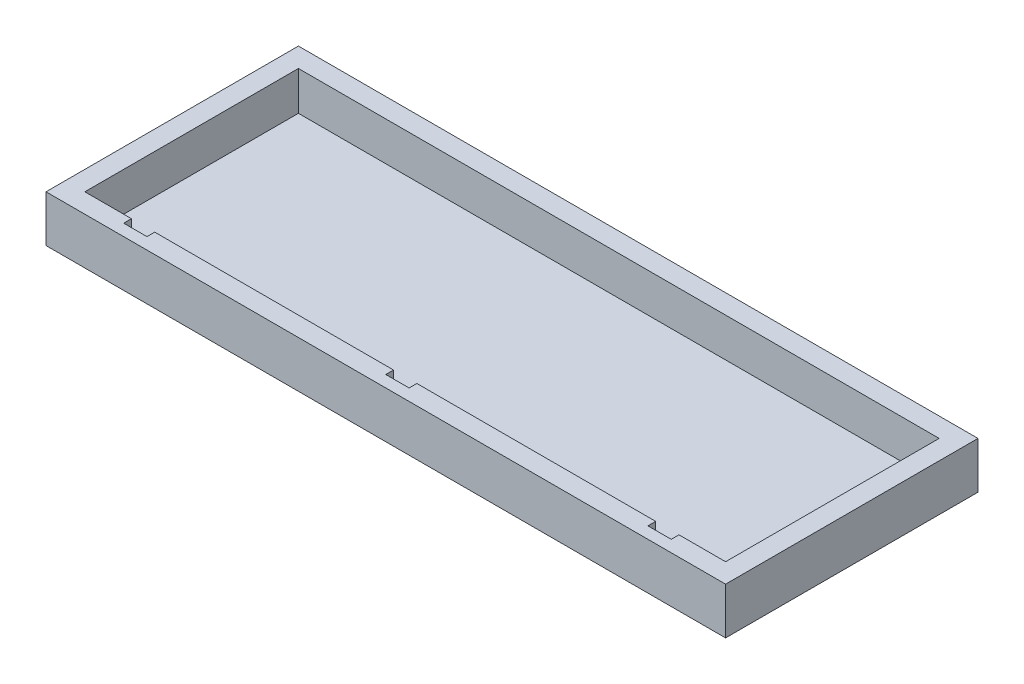
from build123d import *

# Parameters (mm, degrees)
SKETCH1_W           = 175
SKETCH1_H           = 65
BOSS_EXTRUDE1_DEPTH = 12
SKETCH2_W           = 165
SKETCH2_H           = 55
CUT_EXTRUDE1_DEPTH  = 10
SKETCH5_W           = 6
SKETCH5_H           = 10
CUT_EXTRUDE2_DEPTH  = 2
SKETCH6_W           = 6
SKETCH6_H           = 10
CUT_EXTRUDE3_DEPTH  = 2
SKETCH7_W           = 6
SKETCH7_H           = 10
CUT_EXTRUDE4_DEPTH  = 2


with BuildPart() as part:
    # Sketch1 → Boss-Extrude1 (new body)
    with BuildSketch(Plane(origin=(0, 0, 0), x_dir=(1, 0, 0), z_dir=(0, 1, 0))):
        Rectangle(SKETCH1_W, SKETCH1_H)
    extrude(amount=BOSS_EXTRUDE1_DEPTH)

    # Sketch2 → Cut-Extrude1 (cut)
    with BuildSketch(Plane(origin=(0, 12, 0), x_dir=(1, 0, 0), z_dir=(0, 1, 0))):
        Rectangle(SKETCH2_W, SKETCH2_H)
    extrude(amount=-CUT_EXTRUDE1_DEPTH, mode=Mode.SUBTRACT)

    # Sketch5 → Cut-Extrude2 (cut)
    with BuildSketch(Plane(origin=(0, 0, 27.5), x_dir=(-1, 0, 0), z_dir=(0, 0, -1))):
        with Locations((0, 7)):
            Rectangle(SKETCH5_W, SKETCH5_H)
    extrude(amount=-CUT_EXTRUDE2_DEPTH, mode=Mode.SUBTRACT)

    # Sketch6 → Cut-Extrude3 (cut)
    with BuildSketch(Plane(origin=(0, 0, 27.5), x_dir=(-1, 0, 0), z_dir=(0, 0, -1))):
        with Locations((-67.5, 7)):
            Rectangle(SKETCH6_W, SKETCH6_H)
    extrude(amount=-CUT_EXTRUDE3_DEPTH, mode=Mode.SUBTRACT)

    # Sketch7 → Cut-Extrude4 (cut)
    with BuildSketch(Plane(origin=(0, 0, 27.5), x_dir=(-1, 0, 0), z_dir=(0, 0, -1))):
        with Locations((67.5, 7)):
            Rectangle(SKETCH7_W, SKETCH7_H)
    extrude(amount=-CUT_EXTRUDE4_DEPTH, mode=Mode.SUBTRACT)


solid = part.part
